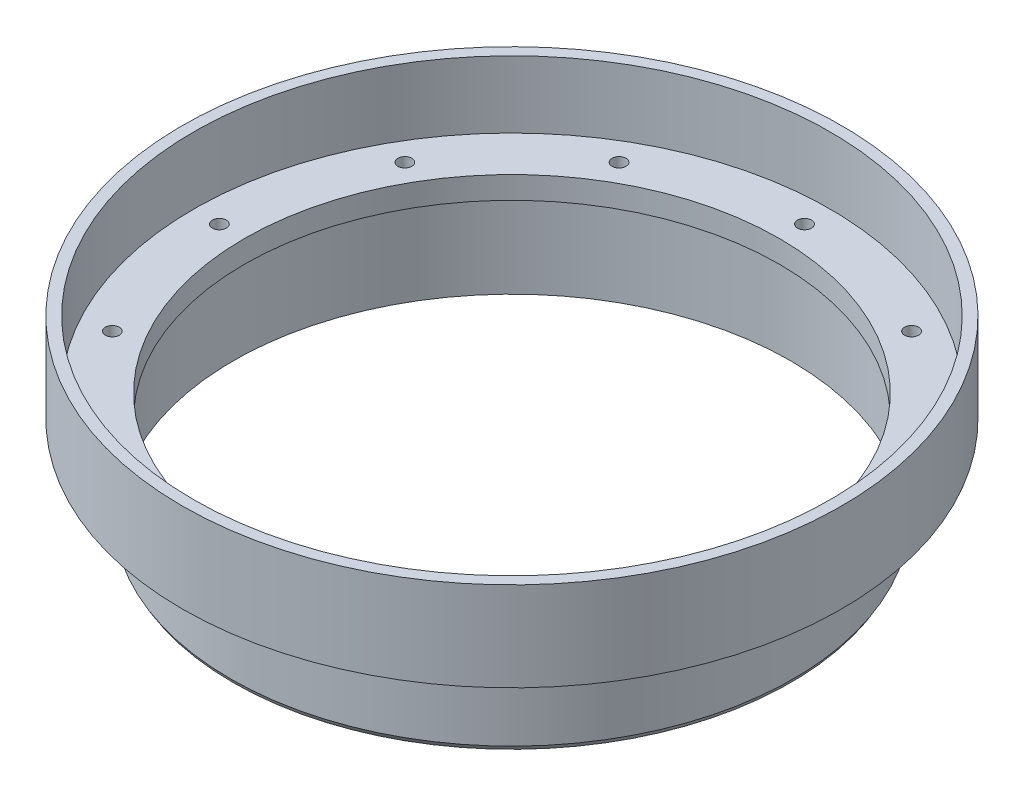
from build123d import *

# Parameters (mm, degrees)
SCREW_HOLES_COUNT = 12


with BuildPart() as part:
    # Cross Section → Main (revolve)
    with BuildSketch(Plane.XY):
        Polygon((-38.1, 0), (-38.1, -3.175), (-39.6875, -3.175), (-39.6875, -15.875), (-40.0685, -15.215088642), (-40.0685, -3.175), (-46.9265, -3.175), (-46.9265, 9.525), (-45.339, 9.525), (-45.339, 0), align=None)
    revolve(axis=Axis((0, 55, 0), (0, -1, 0)))

    # Sketch7 → #3-48 Tapped Hole1 (revolve, cut)
    with BuildSketch(Plane(origin=(-41.656, 0, 0), x_dir=(0, 0, 1), z_dir=(1, 0, 0))):
        Polygon((0, 0), (0, 3.901027994), (0.99695, 3.302), (0.99695, 0), align=None)
    f_3_48_tapped_hole1 = revolve(axis=Axis((-41.656, 6.35, 0), (0, -1, 0)), mode=Mode.SUBTRACT)

    # Screw Holes: #3-48 Tapped Hole1 ×12 about axis
    screw_holes_axis = Axis((0, 0, 0), (0, 1, 0))
    for i in range(1, SCREW_HOLES_COUNT):
        add(f_3_48_tapped_hole1.rotate(screw_holes_axis, i * 360 / SCREW_HOLES_COUNT), mode=Mode.SUBTRACT)


solid = part.part
